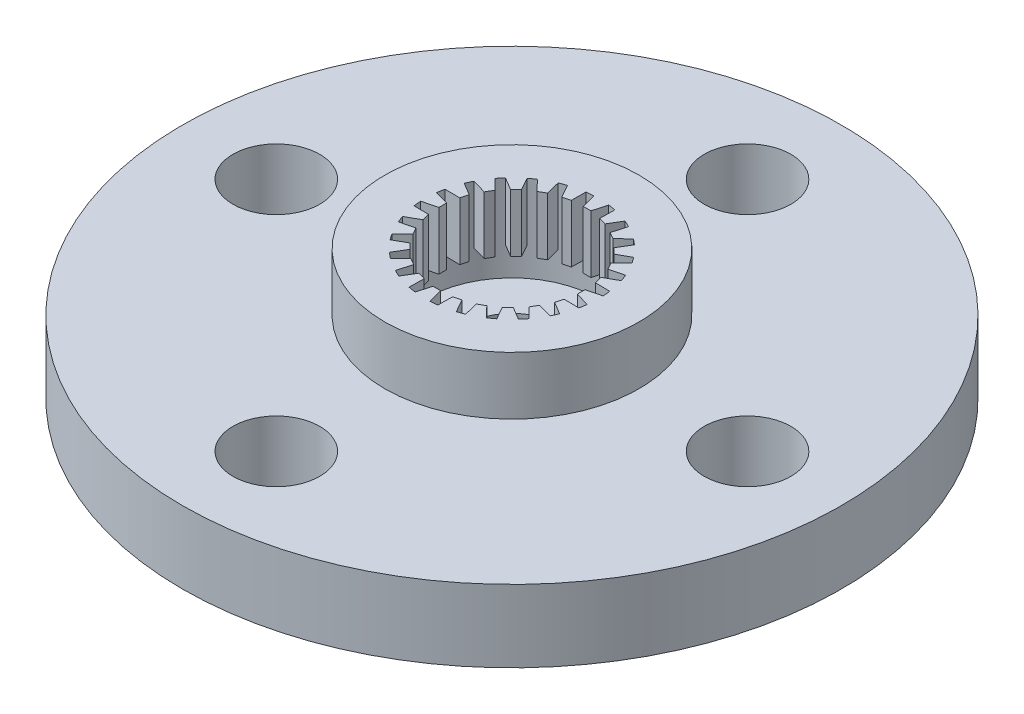
from build123d import *

# Parameters (mm, degrees)
SKETCH_4_R               = 11.4
EXTRUDE_2_DEPTH          = 2.5
SKETCH_6_R               = 1.5
CUT_EXTRUDE_9_DEPTH      = 2.5
SKETCH_7_R               = 4.4
EXTRUDE_3_DEPTH          = 2
SKETCH_8_R               = 3
CUT_EXTRUDE_10_DEPTH     = 3
EXTRUDE_5_DEPTH          = 2
PATTERN_CIRCULAR_1_COUNT = 24


with BuildPart() as part:
    # 草图4 → 凸台-拉伸2 (new body)
    with BuildSketch(Plane(origin=(0, 0, 0), x_dir=(1, 0, 0), z_dir=(0, 1, 0))):
        Circle(SKETCH_4_R)
    extrude(amount=EXTRUDE_2_DEPTH)

    # 草图6 → 切除-拉伸9 (cut)
    with BuildSketch(Plane(origin=(0, 2.5, 0), x_dir=(1, 0, 0), z_dir=(0, 1, 0))):
        with Locations((0, 8.15)):
            Circle(SKETCH_6_R)
        Circle(SKETCH_6_R)
        with Locations((8.15, 0)):
            Circle(SKETCH_6_R)
        with Locations((-8.15, 0)):
            Circle(SKETCH_6_R)
        with Locations((0, -8.15)):
            Circle(SKETCH_6_R)
    extrude(amount=-CUT_EXTRUDE_9_DEPTH, mode=Mode.SUBTRACT)

    # 草图7 → 凸台-拉伸3 (add)
    with BuildSketch(Plane(origin=(0, 2.5, 0), x_dir=(1, 0, 0), z_dir=(0, 1, 0))):
        Circle(SKETCH_7_R)
    extrude(amount=EXTRUDE_3_DEPTH)

    # 草图8 → 切除-拉伸10 (cut)
    with BuildSketch(Plane(origin=(0, 4.5, 0), x_dir=(1, 0, 0), z_dir=(0, 1, 0))):
        Circle(SKETCH_8_R)
    extrude(amount=-CUT_EXTRUDE_10_DEPTH, mode=Mode.SUBTRACT)

    # 草图14 → 凸台-拉伸5 (add)
    with BuildSketch(Plane(origin=(0, 4.5, 0), x_dir=(1, 0, 0), z_dir=(0, 1, 0))):
        with BuildLine():
            Line((2.976910005, -0.371492698), (2.495792863, -0.23538136))
            Line((2.495792863, -0.23538136), (2.495792863, 0.032272898))
            Line((2.495792863, 0.032272898), (2.995792863, 0.158824181))
            ThreePointArc((2.995792863, 0.158824181), (2.998100046, -0.106752588), (2.976910005, -0.371492698))
        make_face()
    extrude_5 = extrude(amount=-EXTRUDE_5_DEPTH)

    # 阵列(圆周)1: 凸台-拉伸5 ×24 about axis
    pattern_circular_1_axis = Axis((0, 4.5, 0), (0, 1, 0))
    for i in range(1, PATTERN_CIRCULAR_1_COUNT):
        add(extrude_5.rotate(pattern_circular_1_axis, i * 360 / PATTERN_CIRCULAR_1_COUNT))


solid = part.part
